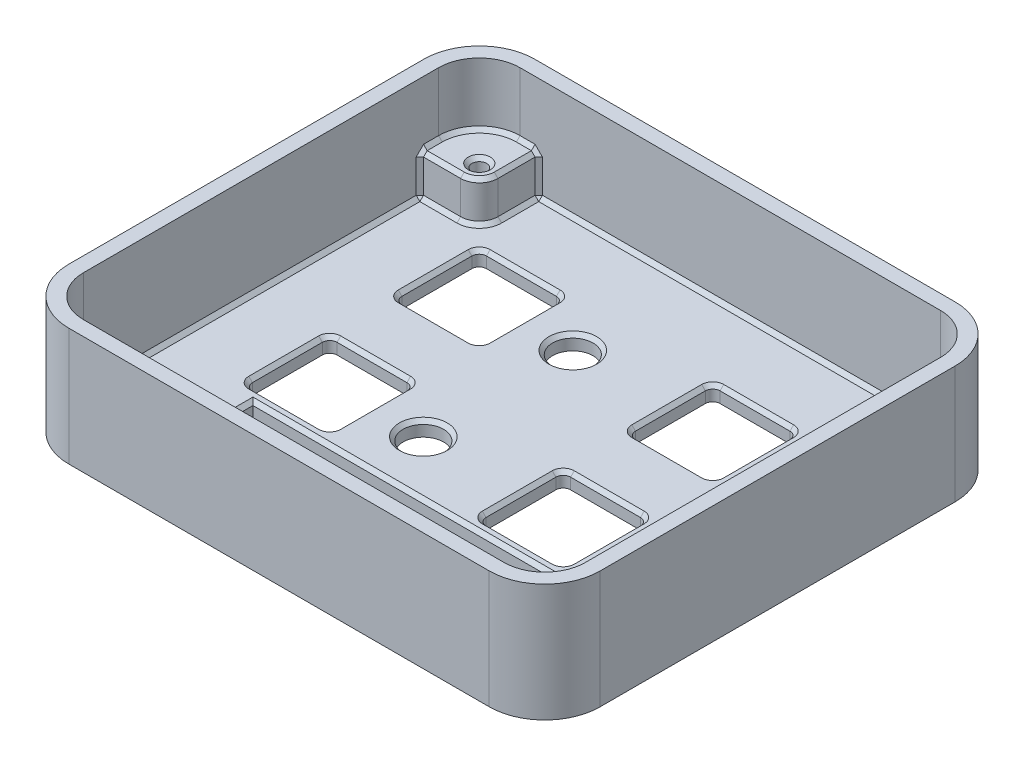
from build123d import *

# Parameters (mm, degrees)
SKETCH1_W           = 72.23
SKETCH1_H           = 63.34
BOSS_EXTRUDE1_DEPTH = 16
FILLET1_R           = 7.54
SHELL1_T            = -2
SKETCH2_R           = 2.75
SKETCH2_W           = 41.64
SKETCH2_H           = 10.8
CUT_EXTRUDE1_DEPTH  = 17
SKETCH3_R           = 1
BOSS_EXTRUDE2_DEPTH = 5.5
CHAMFER1_SIZE       = 0.5


with BuildPart() as part:
    # Sketch1 → Boss-Extrude1 (new body)
    with BuildSketch(Plane(origin=(0, 0, 0), x_dir=(1, 0, 0), z_dir=(0, 1, 0))):
        Rectangle(SKETCH1_W, SKETCH1_H)
    extrude(amount=BOSS_EXTRUDE1_DEPTH)

    # Fillet1
    fillet1_edges = [part.edges().sort_by_distance(p)[0] for p in [
        (-36.115, 8, -31.67),
        (36.115, 8, -31.67),
        (36.115, 8, 31.67),
        (-36.115, 8, 31.67),
    ]]
    fillet(fillet1_edges, radius=FILLET1_R)

    # Shell1
    shell1_openings = [part.faces().sort_by_distance(p)[0] for p in [
        (0, 16, 0),
    ]]
    offset(amount=SHELL1_T, openings=shell1_openings, kind=Kind.INTERSECTION)

    # Sketch2 → Cut-Extrude1 (cut, through all)
    with BuildSketch(Plane(origin=(0, 0, 0), x_dir=(1, 0, 0), z_dir=(0, 1, 0))):
        with Locations((-5.705, 13.97)):
            Circle(SKETCH2_R)
        with Locations((26.045, 13.97)):
            Circle(SKETCH2_R)
        with Locations((26.045, -6.35)):
            Circle(SKETCH2_R)
        with Locations((-5.705, -6.35)):
            Circle(SKETCH2_R)
        with BuildLine():
            Line((-23.185, 19.72), (-13.685, 19.72))
            ThreePointArc((-13.685, 19.72), (-12.977893219, 19.427106781), (-12.685, 18.72))
            Line((-12.685, 18.72), (-12.685, 9.22))
            ThreePointArc((-12.685, 9.22), (-12.977893219, 8.512893219), (-13.685, 8.22))
            Line((-13.685, 8.22), (-23.185, 8.22))
            ThreePointArc((-23.185, 8.22), (-23.892106781, 8.512893219), (-24.185, 9.22))
            Line((-24.185, 9.22), (-24.185, 18.72))
            ThreePointArc((-24.185, 18.72), (-23.892106781, 19.427106781), (-23.185, 19.72))
        make_face()
        with BuildLine():
            Line((8.565, 19.72), (18.065, 19.72))
            ThreePointArc((18.065, 19.72), (18.772106781, 19.427106781), (19.065, 18.72))
            Line((19.065, 18.72), (19.065, 9.22))
            ThreePointArc((19.065, 9.22), (18.772106781, 8.512893219), (18.065, 8.22))
            Line((18.065, 8.22), (8.565, 8.22))
            ThreePointArc((8.565, 8.22), (7.857893219, 8.512893219), (7.565, 9.22))
            Line((7.565, 9.22), (7.565, 18.72))
            ThreePointArc((7.565, 18.72), (7.857893219, 19.427106781), (8.565, 19.72))
        make_face()
        with BuildLine():
            Line((8.565, -0.6), (18.065, -0.6))
            ThreePointArc((18.065, -0.6), (18.772106781, -0.892893219), (19.065, -1.6))
            Line((19.065, -1.6), (19.065, -11.1))
            ThreePointArc((19.065, -11.1), (18.772106781, -11.807106781), (18.065, -12.1))
            Line((18.065, -12.1), (8.565, -12.1))
            ThreePointArc((8.565, -12.1), (7.857893219, -11.807106781), (7.565, -11.1))
            Line((7.565, -11.1), (7.565, -1.6))
            ThreePointArc((7.565, -1.6), (7.857893219, -0.892893219), (8.565, -0.6))
        make_face()
        with BuildLine():
            Line((-23.185, -0.6), (-13.685, -0.6))
            ThreePointArc((-13.685, -0.6), (-12.977893219, -0.892893219), (-12.685, -1.6))
            Line((-12.685, -1.6), (-12.685, -11.1))
            ThreePointArc((-12.685, -11.1), (-12.977893219, -11.807106781), (-13.685, -12.1))
            Line((-13.685, -12.1), (-23.185, -12.1))
            ThreePointArc((-23.185, -12.1), (-23.892106781, -11.807106781), (-24.185, -11.1))
            Line((-24.185, -11.1), (-24.185, -1.6))
            ThreePointArc((-24.185, -1.6), (-23.892106781, -0.892893219), (-23.185, -0.6))
        make_face()
        with Locations((-0.635, -19.162)):
            Rectangle(SKETCH2_W, SKETCH2_H)
    extrude(amount=CUT_EXTRUDE1_DEPTH, mode=Mode.SUBTRACT)

    # Sketch3 → Boss-Extrude2 (add)
    with BuildSketch(Plane(origin=(0, 2, 0), x_dir=(1, 0, 0), z_dir=(0, 1, 0))):
        with BuildLine():
            Line((-28.575, 21.59), (-35.115, 21.59))
            Line((-35.115, 21.59), (-35.115, 24.13))
            ThreePointArc((-35.115, 24.13), (-33.199478349, 28.754478349), (-28.575, 30.67))
            Line((-28.575, 30.67), (-26.035, 30.67))
            Line((-26.035, 30.67), (-26.035, 24.13))
            ThreePointArc((-26.035, 24.13), (-26.778948776, 22.333948776), (-28.575, 21.59))
        make_face()
        with Locations((-28.575, 24.13)):
            Circle(SKETCH3_R, mode=Mode.SUBTRACT)
        with BuildLine():
            Line((-28.575, -30.67), (-26.035, -30.67))
            Line((-26.035, -30.67), (-26.035, -24.13))
            ThreePointArc((-26.035, -24.13), (-26.778948776, -22.333948776), (-28.575, -21.59))
            Line((-28.575, -21.59), (-35.115, -21.59))
            Line((-35.115, -21.59), (-35.115, -24.13))
            ThreePointArc((-35.115, -24.13), (-33.199478349, -28.754478349), (-28.575, -30.67))
        make_face()
        with Locations((-28.575, -24.13)):
            Circle(SKETCH3_R, mode=Mode.SUBTRACT)
        with BuildLine():
            Line((28.575, -21.59), (35.115, -21.59))
            Line((35.115, -21.59), (35.115, -24.13))
            ThreePointArc((35.115, -24.13), (33.199478349, -28.754478349), (28.575, -30.67))
            Line((28.575, -30.67), (26.035, -30.67))
            Line((26.035, -30.67), (26.035, -24.13))
            ThreePointArc((26.035, -24.13), (26.778948776, -22.333948776), (28.575, -21.59))
        make_face()
        with Locations((28.575, -24.13)):
            Circle(SKETCH3_R, mode=Mode.SUBTRACT)
        with BuildLine():
            Line((28.575, 30.67), (26.035, 30.67))
            Line((26.035, 30.67), (26.035, 24.13))
            ThreePointArc((26.035, 24.13), (26.778948776, 22.333948776), (28.575, 21.59))
            Line((28.575, 21.59), (35.115, 21.59))
            Line((35.115, 21.59), (35.115, 24.13))
            ThreePointArc((35.115, 24.13), (33.199478349, 28.754478349), (28.575, 30.67))
        make_face()
        with Locations((28.575, 24.13)):
            Circle(SKETCH3_R, mode=Mode.SUBTRACT)
    extrude(amount=BOSS_EXTRUDE2_DEPTH)

    # Chamfer1
    chamfer1_edges = [part.edges().sort_by_distance(p)[0] for p in [
        (-18.435, 2, 12.1),
        (-23.892106781, 2, 11.807106781),
        (-24.185, 2, 6.35),
        (-23.892106781, 2, 0.892893219),
        (-18.435, 2, 0.6),
        (-12.977893219, 2, 0.892893219),
        (-12.685, 2, 6.35),
        (-12.977893219, 2, 11.807106781),
        (19.065, 2, -13.97),
        (18.772106781, 2, -8.512893219),
        (13.315, 2, -8.22),
        (7.857893219, 2, -8.512893219),
        (7.565, 2, -13.97),
        (7.857893219, 2, -19.427106781),
        (13.315, 2, -19.72),
        (18.772106781, 2, -19.427106781),
        (-24.185, 2, -13.97),
        (-23.892106781, 2, -19.427106781),
        (-18.435, 2, -19.72),
        (-12.977893219, 2, -19.427106781),
        (-12.685, 2, -13.97),
        (-12.977893219, 2, -8.512893219),
        (-18.435, 2, -8.22),
        (-23.892106781, 2, -8.512893219),
        (-32.492371568, 7.5, -28.047371568),
        (-26.035, 4.75, -29.67),
        (-34.115, 2, 0),
        (-34.115, 4.75, -21.59),
        (-34.115, 7.5, -22.86),
        (-31.345, 7.5, -21.59),
        (-26.778948776, 7.5, -22.333948776),
        (-26.035, 7.5, -26.9),
        (-27.305, 7.5, -29.67),
        (-31.345, 2, -21.59),
        (-26.778948776, 2, -22.333948776),
        (-26.035, 2, -26.9),
        (-29.575, 7.5, -24.13),
        (-32.492371568, 7.5, 28.047371568),
        (0, 2, 29.67),
        (-26.035, 4.75, 29.67),
        (-34.115, 4.75, 21.59),
        (-34.115, 7.5, 22.86),
        (-27.305, 7.5, 29.67),
        (-26.035, 7.5, 26.9),
        (-26.778948776, 7.5, 22.333948776),
        (-31.345, 7.5, 21.59),
        (-31.345, 2, 21.59),
        (-26.035, 2, 26.9),
        (-26.778948776, 2, 22.333948776),
        (-29.575, 7.5, 24.13),
        (32.492371568, 7.5, 28.047371568),
        (34.115, 2, 0),
        (34.115, 4.75, 21.59),
        (26.035, 4.75, 29.67),
        (26.035, 7.5, 26.9),
        (27.305, 7.5, 29.67),
        (34.115, 7.5, 22.86),
        (31.345, 7.5, 21.59),
        (26.778948776, 7.5, 22.333948776),
        (31.345, 2, 21.59),
        (26.778948776, 2, 22.333948776),
        (26.035, 2, 26.9),
        (27.575, 7.5, 24.13),
        (32.492371568, 7.5, -28.047371568),
        (0, 2, -29.67),
        (26.035, 4.75, -29.67),
        (34.115, 4.75, -21.59),
        (34.115, 7.5, -22.86),
        (27.305, 7.5, -29.67),
        (26.035, 7.5, -26.9),
        (26.778948776, 7.5, -22.333948776),
        (31.345, 7.5, -21.59),
        (31.345, 2, -21.59),
        (26.035, 2, -26.9),
        (26.778948776, 2, -22.333948776),
        (27.575, 7.5, -24.13),
        (-8.455, 2, -13.97),
        (-0.635, 2, 24.562),
        (-21.455, 2, 19.162),
        (-0.635, 2, 13.762),
        (20.185, 2, 19.162),
        (23.295, 2, -13.97),
        (23.295, 2, 6.35),
        (-8.455, 2, 6.35),
        (13.315, 2, 12.1),
        (7.857893219, 2, 11.807106781),
        (7.565, 2, 6.35),
        (7.857893219, 2, 0.892893219),
        (13.315, 2, 0.6),
        (18.772106781, 2, 0.892893219),
        (19.065, 2, 6.35),
        (18.772106781, 2, 11.807106781),
    ]]
    chamfer(chamfer1_edges, length=CHAMFER1_SIZE)


solid = part.part
